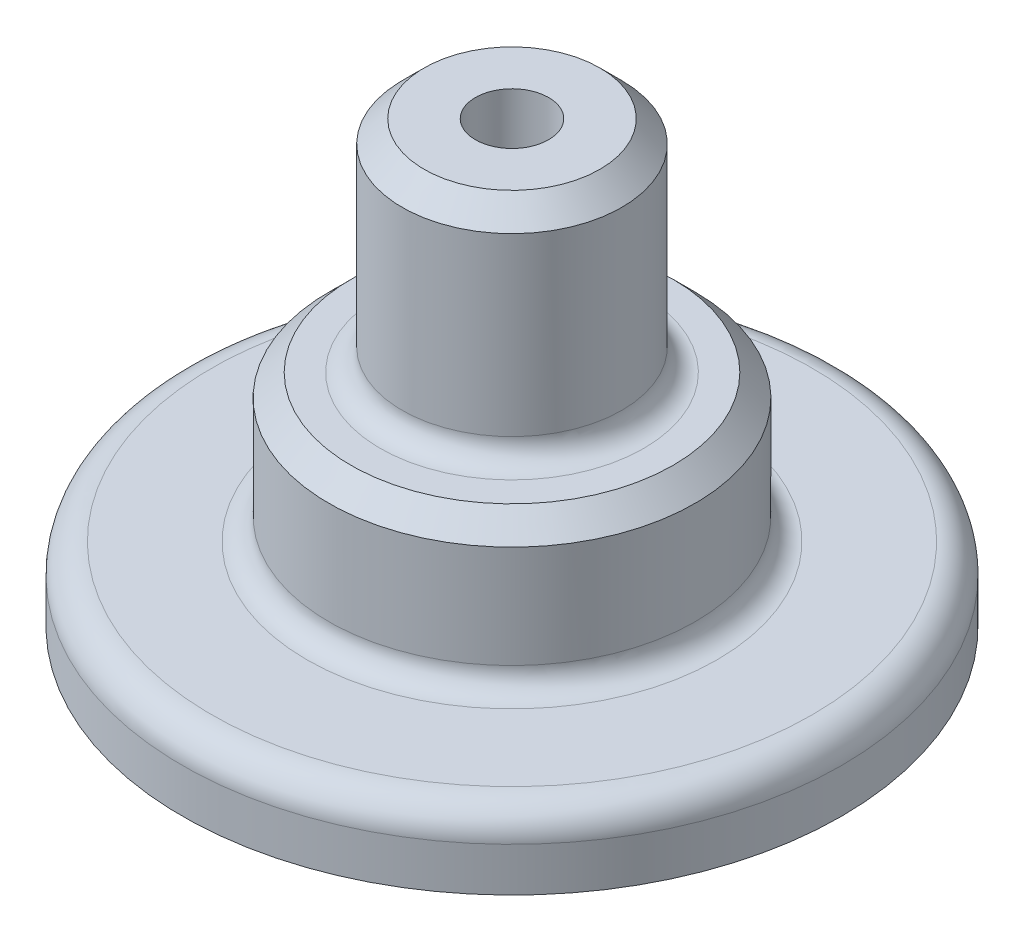
from build123d import *

# Parameters (mm, degrees)
FILLET2_R               = 8
FILLET3_R               = 6
FILLET4_R               = 6
CUT_EXTRUDE2_DEPTH      = 10
CUT_EXTRUDE2_DEPTH_BACK = 181.277563823
SKETCH3_R               = 10
CHAMFER2_SIZE           = 6


with BuildPart() as part:
    # Sketch2 → Revolve1 (revolve)
    with BuildSketch(Plane.XY):
        Polygon((10, 120), (10, 0), (100, 0), (100, 20), (60, 20), (60, 60), (40, 60), (40, 120), align=None)
    revolve(axis=Axis((10, 120, 0), (0, -1, 0)))

    # Fillet2
    fillet2_edges = [part.edges().sort_by_distance(p)[0] for p in [
        (-80, 20, 0),
    ]]
    fillet(fillet2_edges, radius=FILLET2_R)

    # Fillet3
    fillet3_edges = [part.edges().sort_by_distance(p)[0] for p in [
        (-40, 20, 0),
    ]]
    fillet(fillet3_edges, radius=FILLET3_R)

    # Fillet4
    fillet4_edges = [part.edges().sort_by_distance(p)[0] for p in [
        (-20, 60, 0),
    ]]
    fillet(fillet4_edges, radius=FILLET4_R)

    # Sketch3 → Cut-Extrude2 (cut, two sides: drawn at the far end of the back side and taken through both)
    with BuildSketch(Plane(origin=(0, 120, 0), x_dir=(1, 0, 0), z_dir=(0, 1, 0)).offset(-CUT_EXTRUDE2_DEPTH_BACK)):
        with Locations((10, 0)):
            Circle(SKETCH3_R)
    extrude(amount=CUT_EXTRUDE2_DEPTH + CUT_EXTRUDE2_DEPTH_BACK, mode=Mode.SUBTRACT)

    # Chamfer2
    chamfer2_edges = [part.edges().sort_by_distance(p)[0] for p in [
        (-40, 60, 0),
        (-20, 120, 0),
    ]]
    chamfer(chamfer2_edges, length=CHAMFER2_SIZE)


solid = part.part
